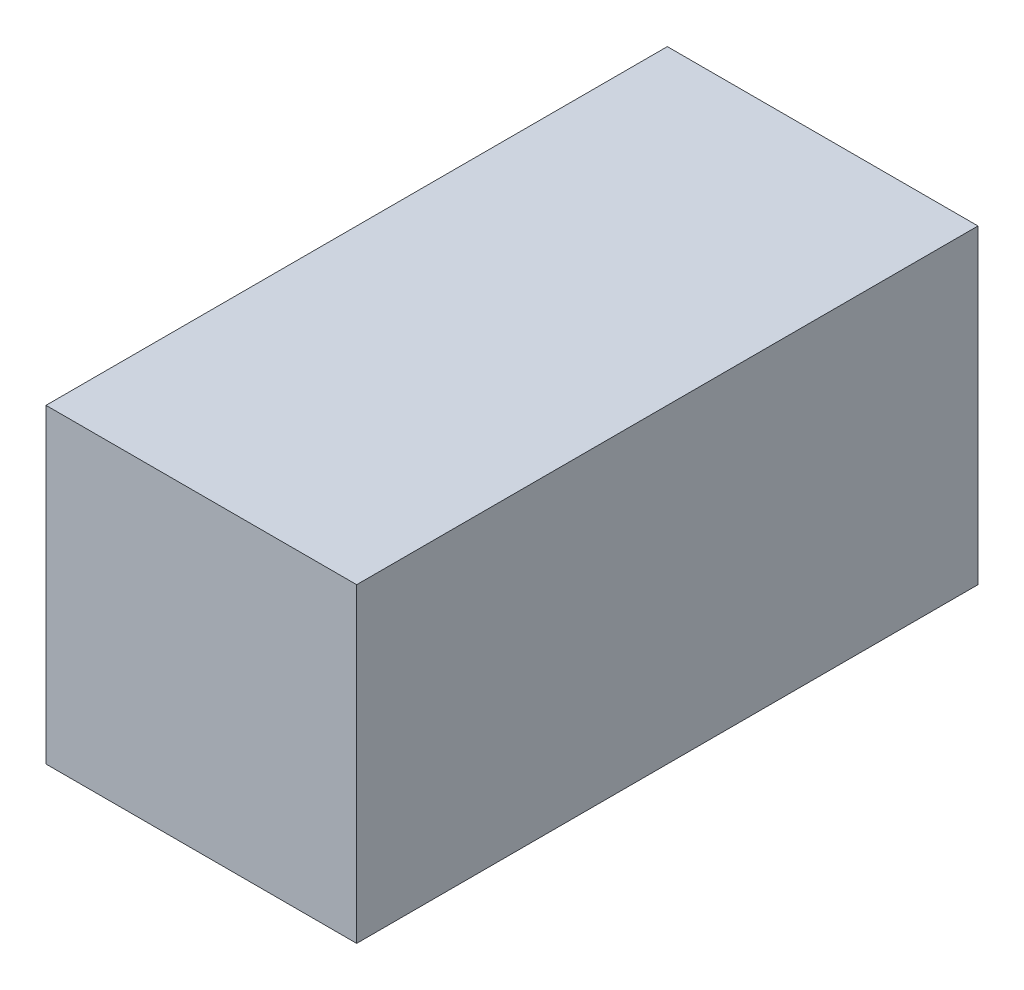
from build123d import *

# Parameters (mm, degrees)
CROQUIS1_W              = 30
CROQUIS1_H              = 30
SALIENTE_EXTRUIR1_DEPTH = 60


with BuildPart() as part:
    # Croquis1 → Saliente-Extruir1 (new body)
    with BuildSketch(Plane.XY):
        with Locations((8.324333554, 8.324333554)):
            Rectangle(CROQUIS1_W, CROQUIS1_H)
    extrude(amount=SALIENTE_EXTRUIR1_DEPTH)


solid = part.part
